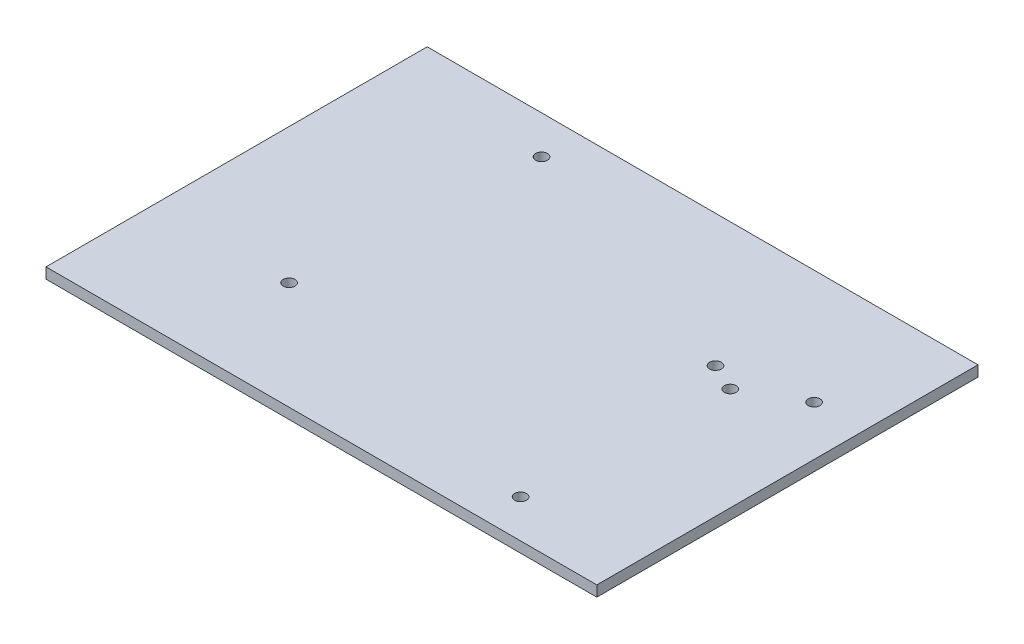
from build123d import *

# Parameters (mm, degrees)
SKETCH1_W           = 144.5
SKETCH1_H           = 100
SKETCH1_R           = 1.55
BOSS_EXTRUDE1_DEPTH = 2.8
CUT_EXTRUDE1_REACH  = 4.8
SKETCH2_R           = 1.55
CUT_EXTRUDE2_REACH  = 4.8
SKETCH3_R           = 1.55


with BuildPart() as part:
    # Sketch1 → Boss-Extrude1 (new body)
    with BuildSketch(Plane(origin=(0, 0, 0), x_dir=(1, 0, 0), z_dir=(0, 1, 0))):
        Rectangle(SKETCH1_W, SKETCH1_H)
        with Locations((-32.25, 40)):
            Circle(SKETCH1_R, mode=Mode.SUBTRACT)
        with Locations((59.25, 20)):
            Circle(SKETCH1_R, mode=Mode.SUBTRACT)
        with Locations((42.25, -40)):
            Circle(SKETCH1_R, mode=Mode.SUBTRACT)
    extrude(amount=BOSS_EXTRUDE1_DEPTH)

    # Sketch2 → Cut-Extrude1 (cut, up to next)
    with BuildSketch(Plane(origin=(0, 2.8, 0), x_dir=(1, 0, 0), z_dir=(0, 1, 0)), mode=Mode.PRIVATE) as cut_extrude1_sk1:
        with Locations((-36.75, -21.73)):
            Circle(SKETCH2_R)
    cut_extrude1_tool1 = extrude(cut_extrude1_sk1.sketch, amount=-CUT_EXTRUDE1_REACH, mode=Mode.PRIVATE) & part.part
    add(cut_extrude1_tool1.solids().sort_by_distance((-36.75, 2.8, 21.73))[0], mode=Mode.SUBTRACT)

    # Sketch3 → Cut-Extrude2 (cut, up to next)
    with BuildSketch(Plane(origin=(0, 2.8, 0), x_dir=(1, 0, 0), z_dir=(0, 1, 0)), mode=Mode.PRIVATE) as cut_extrude2_sk1:
        with Locations((37.999537704, 15.380946094)):
            Circle(SKETCH3_R)
    cut_extrude2_tool1 = extrude(cut_extrude2_sk1.sketch, amount=-CUT_EXTRUDE2_REACH, mode=Mode.PRIVATE) & part.part
    add(cut_extrude2_tool1.solids().sort_by_distance((37.999538, 2.8, -15.380946))[0], mode=Mode.SUBTRACT)
    # Sketch3 → Cut-Extrude2 (cut, up to next)
    with BuildSketch(Plane(origin=(0, 2.8, 0), x_dir=(1, 0, 0), z_dir=(0, 1, 0)), mode=Mode.PRIVATE) as cut_extrude2_sk2:
        with Locations((45.25, 12)):
            Circle(SKETCH3_R)
    cut_extrude2_tool2 = extrude(cut_extrude2_sk2.sketch, amount=-CUT_EXTRUDE2_REACH, mode=Mode.PRIVATE) & part.part
    add(cut_extrude2_tool2.solids().sort_by_distance((45.25, 2.8, -12))[0], mode=Mode.SUBTRACT)


solid = part.part
